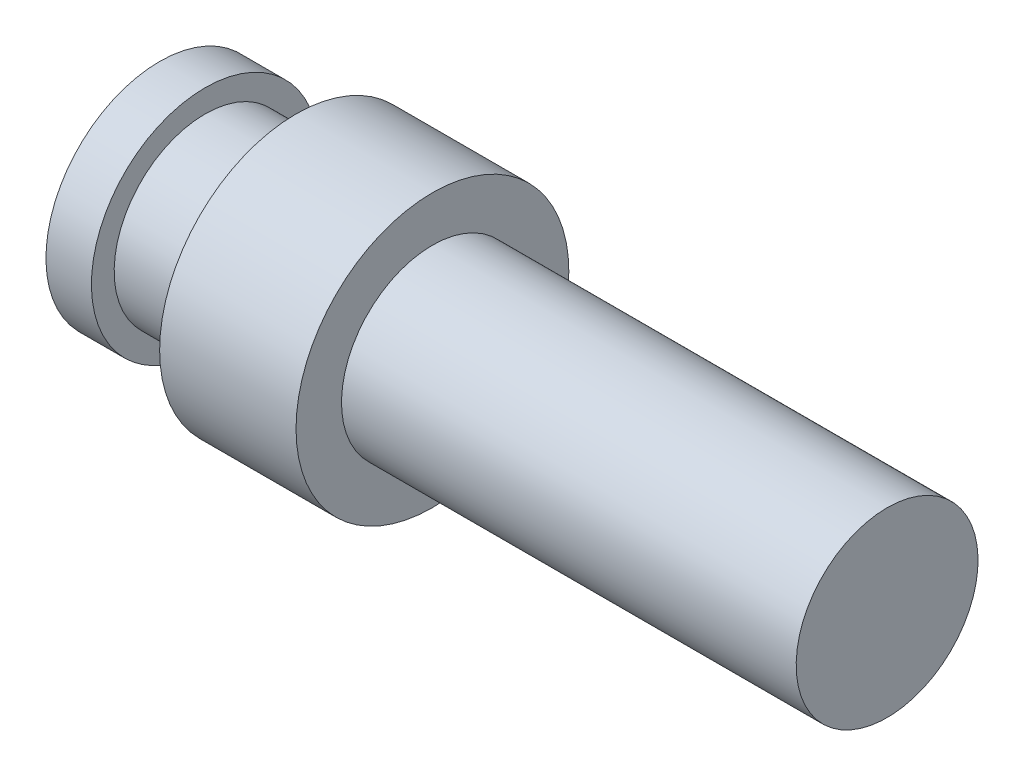
from build123d import *


with BuildPart() as part:
    # Esquisse1 → Révolution1 (revolve)
    with BuildSketch(Plane.XY):
        Polygon((0, 0), (0, 2.5), (1, 2.5), (1, 2), (3, 2), (3, 3), (6, 3), (6, 2), (16, 2), (16, 0), align=None)
    revolve(axis=Axis((16, 0, 0), (-1, 0, 0)))


solid = part.part
